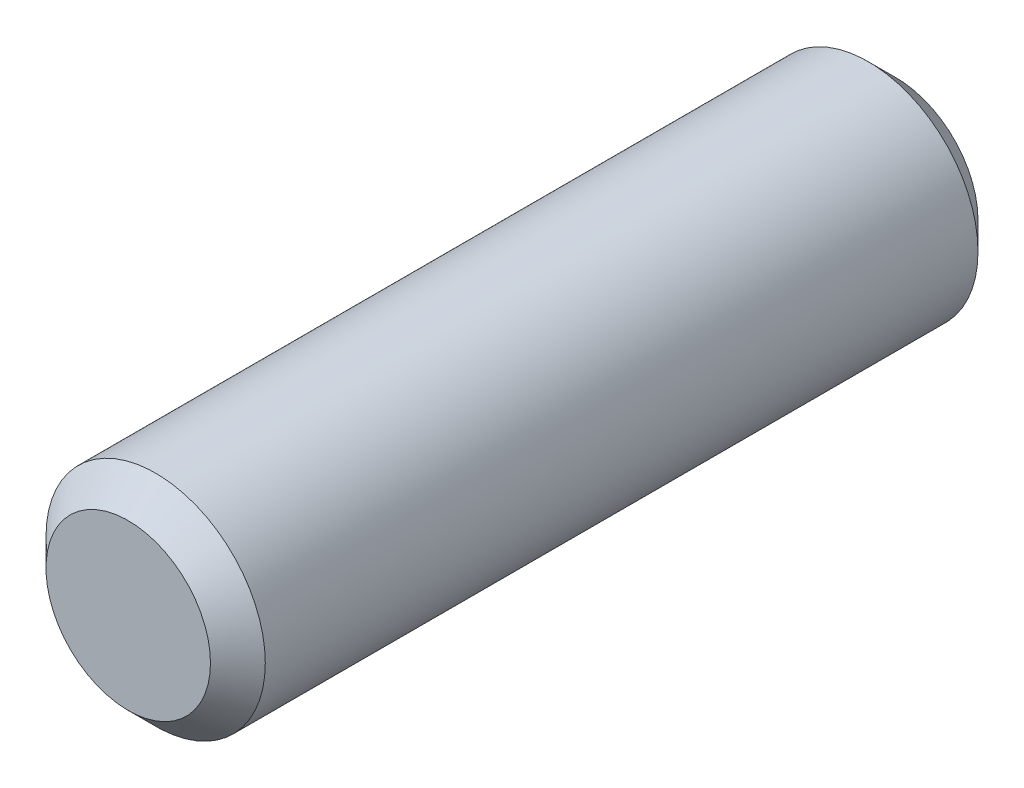
from build123d import *

# Parameters (mm, degrees)
SKETCH1_R           = 2
BOSS_EXTRUDE1_DEPTH = 14
CHAMFER1_SIZE       = 0.5


with BuildPart() as part:
    # Sketch1 → Boss-Extrude1 (new body)
    with BuildSketch(Plane.XY):
        Circle(SKETCH1_R)
    extrude(amount=BOSS_EXTRUDE1_DEPTH)

    # Chamfer1
    chamfer1_edges = [part.edges().sort_by_distance(p)[0] for p in [
        (-2, 0, 0),
        (-2, 0, 14),
    ]]
    chamfer(chamfer1_edges, length=CHAMFER1_SIZE)


solid = part.part
